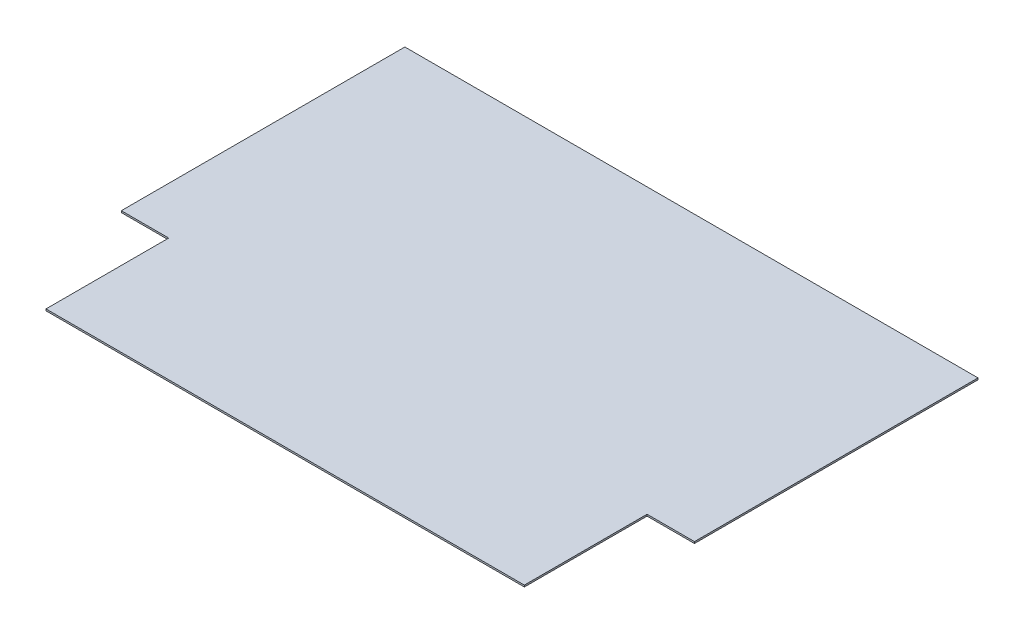
from build123d import *

# Parameters (mm, degrees)
BOSS_EXTRUDE1_DEPTH = 6.35
SKETCH2_W           = 177.8
SKETCH2_H           = 460.375
CUT_EXTRUDE1_DEPTH  = 7.35
SKETCH3_W           = 2150.099514553
SKETCH3_H           = 1524
CUT_EXTRUDE2_DEPTH  = 7.35


with BuildPart() as part:
    # Sketch1 → Boss-Extrude1 (new body)
    with BuildSketch(Plane(origin=(0, 0, 0), x_dir=(1, 0, 0), z_dir=(0, 1, 0))):
        Polygon((-914.4, 0), (914.4, 0), (914.4, 3048), (-914.4, 3048), (-1438.899514553, 3048), (-1438.899514553, 0), align=None)
    extrude(amount=BOSS_EXTRUDE1_DEPTH)

    # Sketch2 → Cut-Extrude1 (cut, through all)
    with BuildSketch(Plane(origin=(0, 6.35, 0), x_dir=(1, 0, 0), z_dir=(0, 1, 0))):
        Polygon((914.4, 0), (533.4, 0), (533.4, 460.375), (711.2, 460.375), (711.2, 2587.625), (533.4, 2587.625), (533.4, 3048), (914.4, 3048), (914.4, 2587.625), (914.4, 460.375), align=None)
        with Locations((-1349.999514553, 230.1875)):
            Rectangle(SKETCH2_W, SKETCH2_H)
        with Locations((-1349.999514553, 2817.8125)):
            Rectangle(SKETCH2_W, SKETCH2_H)
    extrude(amount=-CUT_EXTRUDE1_DEPTH, mode=Mode.SUBTRACT)

    # Sketch3 → Cut-Extrude2 (cut, through all)
    with BuildSketch(Plane(origin=(0, 6.35, 0), x_dir=(1, 0, 0), z_dir=(0, 1, 0))):
        with Locations((-363.849757276, 2286)):
            Rectangle(SKETCH3_W, SKETCH3_H)
    extrude(amount=-CUT_EXTRUDE2_DEPTH, mode=Mode.SUBTRACT)


solid = part.part
